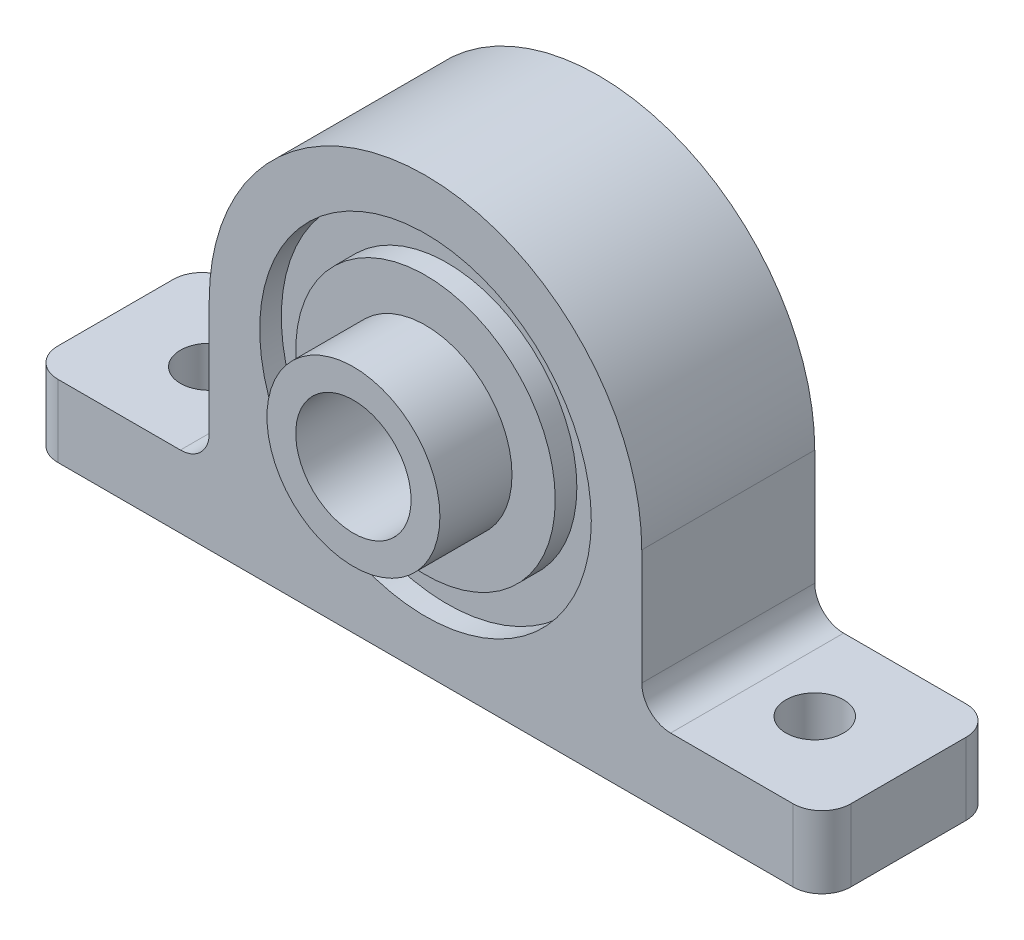
from build123d import *

# Parameters (mm, degrees)
SKETCH_2_R          = 4
EXTRUDE_1_DEPTH     = 12
FILLET_1_R          = 2
SKETCH_3_R          = 2
CUT_EXTRUDE_1_DEPTH = 6
SKETCH_4_R          = 6
SKETCH_4_R_2        = 4
EXTRUDE_2_DEPTH     = 5
SKETCH_5_R          = 11.5
SKETCH_5_R_2        = 9
CUT_EXTRUDE_2_DEPTH = 1.5


with BuildPart() as part:
    # 草图2 → 凸台-拉伸1 (new body)
    with BuildSketch(Plane.XY):
        with BuildLine():
            Line((0, -15), (-27.5, -15))
            Line((-27.5, -15), (-27.5, -10))
            Line((-27.5, -10), (-17, -10))
            ThreePointArc((-17, -10), (-15.585786438, -9.414213562), (-15, -8))
            Line((-15, -8), (-15, 0))
            ThreePointArc((-15, 0), (0, 15), (15, 0))
            Line((15, 0), (15, -8))
            ThreePointArc((15, -8), (15.585786438, -9.414213562), (17, -10))
            Line((17, -10), (27.5, -10))
            Line((27.5, -10), (27.5, -15))
            Line((27.5, -15), (0, -15))
        make_face()
        Circle(SKETCH_2_R, mode=Mode.SUBTRACT)
    extrude(amount=EXTRUDE_1_DEPTH)

    # 圆角1
    fillet_1_edges = [part.edges().sort_by_distance(p)[0] for p in [
        (27.5, -12.5, 0),
        (-27.5, -12.5, 0),
        (-27.5, -12.5, 12),
        (27.5, -12.5, 12),
    ]]
    fillet(fillet_1_edges, radius=FILLET_1_R)

    # 草图3 → 切除-拉伸1 (cut, through all)
    with BuildSketch(Plane(origin=(0, -10, 0), x_dir=(1, 0, 0), z_dir=(0, 1, 0))):
        with Locations((-21, -6)):
            Circle(SKETCH_3_R)
        with Locations((21, -6)):
            Circle(SKETCH_3_R)
    extrude(amount=-CUT_EXTRUDE_1_DEPTH, mode=Mode.SUBTRACT)

    # 草图4 → 凸台-拉伸2 (add)
    with BuildSketch(Plane.XY.offset(12)):
        Circle(SKETCH_4_R)
        Circle(SKETCH_4_R_2, mode=Mode.SUBTRACT)
    extrude(amount=EXTRUDE_2_DEPTH)

    # 草图5 → 切除-拉伸2 (cut)
    with BuildSketch(Plane.XY.offset(12)):
        Circle(SKETCH_5_R)
        Circle(SKETCH_5_R_2, mode=Mode.SUBTRACT)
    cut_extrude_2 = extrude(amount=-CUT_EXTRUDE_2_DEPTH, mode=Mode.SUBTRACT)

    # 镜向1: 切除-拉伸2 across plane
    add(cut_extrude_2.mirror(Plane.XY.offset(6)), mode=Mode.SUBTRACT)


solid = part.part
